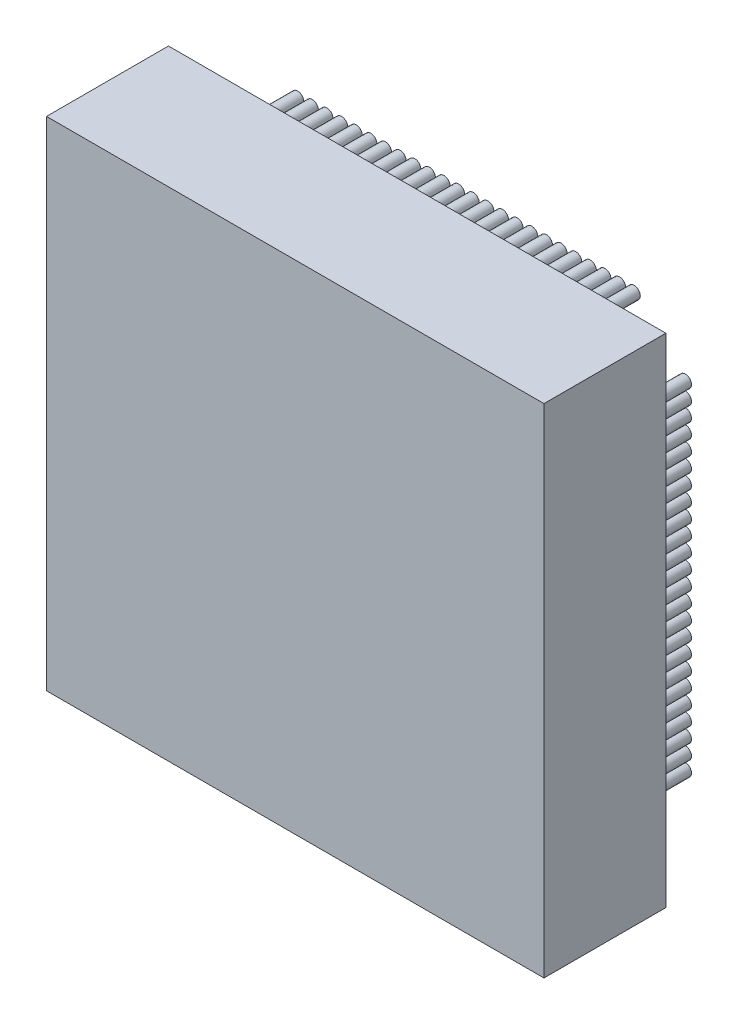
from build123d import *

# Parameters (mm, degrees)
SKETCH1_W               = 20.4
SKETCH1_H               = 20.4
COMPONENT_OUTLINE_DEPTH = 5
SKETCH2_R               = 0.25
EXTRUDE_1_DEPTH         = 2
SKETCH3_R               = 0.25
EXTRUDE_2_DEPTH         = 2
SKETCH4_R               = 0.25
EXTRUDE_3_DEPTH         = 2
SKETCH5_R               = 0.25
EXTRUDE_4_DEPTH         = 2
SKETCH6_R               = 0.25
EXTRUDE_5_DEPTH         = 2
SKETCH7_R               = 0.25
EXTRUDE_6_DEPTH         = 2
SKETCH8_R               = 0.25
EXTRUDE_7_DEPTH         = 2
SKETCH9_R               = 0.25
EXTRUDE_8_DEPTH         = 2
SKETCH10_R              = 0.25
EXTRUDE_9_DEPTH         = 2
SKETCH11_R              = 0.25
EXTRUDE_10_DEPTH        = 2
SKETCH12_R              = 0.25
EXTRUDE_11_DEPTH        = 2
SKETCH13_R              = 0.25
EXTRUDE_12_DEPTH        = 2
SKETCH14_R              = 0.25
EXTRUDE_13_DEPTH        = 2
SKETCH15_R              = 0.25
EXTRUDE_14_DEPTH        = 2
SKETCH16_R              = 0.25
EXTRUDE_15_DEPTH        = 2
SKETCH17_R              = 0.25
EXTRUDE_16_DEPTH        = 2
SKETCH18_R              = 0.25
EXTRUDE_17_DEPTH        = 2
SKETCH19_R              = 0.25
EXTRUDE_18_DEPTH        = 2
SKETCH20_R              = 0.25
EXTRUDE_19_DEPTH        = 2
SKETCH21_R              = 0.25
EXTRUDE_20_DEPTH        = 2
SKETCH22_R              = 0.25
EXTRUDE_21_DEPTH        = 2
SKETCH23_R              = 0.25
EXTRUDE_22_DEPTH        = 2
SKETCH24_R              = 0.25
EXTRUDE_23_DEPTH        = 2
SKETCH25_R              = 0.25
EXTRUDE_24_DEPTH        = 2
SKETCH26_R              = 0.25
EXTRUDE_25_DEPTH        = 2
SKETCH27_R              = 0.25
EXTRUDE_26_DEPTH        = 2
SKETCH28_R              = 0.25
EXTRUDE_27_DEPTH        = 2
SKETCH29_R              = 0.25
EXTRUDE_28_DEPTH        = 2
SKETCH30_R              = 0.25
EXTRUDE_29_DEPTH        = 2
SKETCH31_R              = 0.25
EXTRUDE_30_DEPTH        = 2
SKETCH32_R              = 0.25
EXTRUDE_31_DEPTH        = 2
SKETCH33_R              = 0.25
EXTRUDE_32_DEPTH        = 2
SKETCH34_R              = 0.25
EXTRUDE_33_DEPTH        = 2
SKETCH35_R              = 0.25
EXTRUDE_34_DEPTH        = 2
SKETCH36_R              = 0.25
EXTRUDE_35_DEPTH        = 2
SKETCH37_R              = 0.25
EXTRUDE_36_DEPTH        = 2
SKETCH38_R              = 0.25
EXTRUDE_37_DEPTH        = 2
SKETCH39_R              = 0.25
EXTRUDE_38_DEPTH        = 2
SKETCH40_R              = 0.25
EXTRUDE_39_DEPTH        = 2
SKETCH41_R              = 0.25
EXTRUDE_40_DEPTH        = 2
SKETCH42_R              = 0.25
EXTRUDE_41_DEPTH        = 2
SKETCH43_R              = 0.25
EXTRUDE_42_DEPTH        = 2
SKETCH44_R              = 0.25
EXTRUDE_43_DEPTH        = 2
SKETCH45_R              = 0.25
EXTRUDE_44_DEPTH        = 2
SKETCH46_R              = 0.25
EXTRUDE_45_DEPTH        = 2
SKETCH47_R              = 0.25
EXTRUDE_46_DEPTH        = 2
SKETCH48_R              = 0.25
EXTRUDE_47_DEPTH        = 2
SKETCH49_R              = 0.25
EXTRUDE_48_DEPTH        = 2
SKETCH50_R              = 0.25
EXTRUDE_49_DEPTH        = 2
SKETCH51_R              = 0.25
EXTRUDE_50_DEPTH        = 2
SKETCH52_R              = 0.25
EXTRUDE_51_DEPTH        = 2
SKETCH53_R              = 0.25
EXTRUDE_52_DEPTH        = 2
SKETCH54_R              = 0.25
EXTRUDE_53_DEPTH        = 2
SKETCH55_R              = 0.25
EXTRUDE_54_DEPTH        = 2
SKETCH56_R              = 0.25
EXTRUDE_55_DEPTH        = 2
SKETCH57_R              = 0.25
EXTRUDE_56_DEPTH        = 2
SKETCH58_R              = 0.25
EXTRUDE_57_DEPTH        = 2
SKETCH59_R              = 0.25
EXTRUDE_58_DEPTH        = 2
SKETCH60_R              = 0.25
EXTRUDE_59_DEPTH        = 2
SKETCH61_R              = 0.25
EXTRUDE_60_DEPTH        = 2
SKETCH62_R              = 0.25
EXTRUDE_61_DEPTH        = 2
SKETCH63_R              = 0.25
EXTRUDE_62_DEPTH        = 2
SKETCH64_R              = 0.25
EXTRUDE_63_DEPTH        = 2
SKETCH65_R              = 0.25
EXTRUDE_64_DEPTH        = 2
SKETCH66_R              = 0.25
EXTRUDE_65_DEPTH        = 2
SKETCH67_R              = 0.25
EXTRUDE_66_DEPTH        = 2
SKETCH68_R              = 0.25
EXTRUDE_67_DEPTH        = 2
SKETCH69_R              = 0.25
EXTRUDE_68_DEPTH        = 2
SKETCH70_R              = 0.25
EXTRUDE_69_DEPTH        = 2
SKETCH71_R              = 0.25
EXTRUDE_70_DEPTH        = 2
SKETCH72_R              = 0.25
EXTRUDE_71_DEPTH        = 2
SKETCH73_R              = 0.25
EXTRUDE_72_DEPTH        = 2
SKETCH74_R              = 0.25
EXTRUDE_73_DEPTH        = 2
SKETCH75_R              = 0.25
EXTRUDE_74_DEPTH        = 2
SKETCH76_R              = 0.25
EXTRUDE_75_DEPTH        = 2
SKETCH77_R              = 0.25
EXTRUDE_76_DEPTH        = 2
SKETCH78_R              = 0.25
EXTRUDE_77_DEPTH        = 2
SKETCH79_R              = 0.25
EXTRUDE_78_DEPTH        = 2
SKETCH80_R              = 0.25
EXTRUDE_79_DEPTH        = 2
SKETCH81_R              = 0.25
EXTRUDE_80_DEPTH        = 2
SKETCH82_R              = 0.25
EXTRUDE_81_DEPTH        = 2
SKETCH83_R              = 0.25
EXTRUDE_82_DEPTH        = 2
SKETCH84_R              = 0.25
EXTRUDE_83_DEPTH        = 2
SKETCH85_R              = 0.25
EXTRUDE_84_DEPTH        = 2
SKETCH86_R              = 0.25
EXTRUDE_85_DEPTH        = 2
SKETCH87_R              = 0.25
EXTRUDE_86_DEPTH        = 2
SKETCH88_R              = 0.25
EXTRUDE_87_DEPTH        = 2
SKETCH89_R              = 0.25
EXTRUDE_88_DEPTH        = 2
SKETCH90_R              = 0.25
EXTRUDE_89_DEPTH        = 2
SKETCH91_R              = 0.25
EXTRUDE_90_DEPTH        = 2
SKETCH92_R              = 0.25
EXTRUDE_91_DEPTH        = 2
SKETCH93_R              = 0.25
EXTRUDE_92_DEPTH        = 2
SKETCH94_R              = 0.25
EXTRUDE_93_DEPTH        = 2
SKETCH95_R              = 0.25
EXTRUDE_94_DEPTH        = 2
SKETCH96_R              = 0.25
EXTRUDE_95_DEPTH        = 2
SKETCH97_R              = 0.25
EXTRUDE_96_DEPTH        = 2


with BuildPart() as part:
    # Sketch1 → Component_Outline (new body)
    with BuildSketch(Plane.XY):
        Rectangle(SKETCH1_W, SKETCH1_H)
    extrude(amount=COMPONENT_OUTLINE_DEPTH)


with BuildPart() as body_2:
    # Sketch2 → Extrude 1 (new body)
    with BuildSketch(Plane.XY):
        with Locations((-6.9, -9)):
            Circle(SKETCH2_R)
    extrude(amount=-EXTRUDE_1_DEPTH)


with BuildPart() as body_3:
    # Sketch3 → Extrude 2 (new body)
    with BuildSketch(Plane.XY):
        with Locations((-6.3, -9)):
            Circle(SKETCH3_R)
    extrude(amount=-EXTRUDE_2_DEPTH)


with BuildPart() as body_4:
    # Sketch4 → Extrude 3 (new body)
    with BuildSketch(Plane.XY):
        with Locations((-5.7, -9)):
            Circle(SKETCH4_R)
    extrude(amount=-EXTRUDE_3_DEPTH)


with BuildPart() as body_5:
    # Sketch5 → Extrude 4 (new body)
    with BuildSketch(Plane.XY):
        with Locations((-5.1, -9)):
            Circle(SKETCH5_R)
    extrude(amount=-EXTRUDE_4_DEPTH)


with BuildPart() as body_6:
    # Sketch6 → Extrude 5 (new body)
    with BuildSketch(Plane.XY):
        with Locations((-4.5, -9)):
            Circle(SKETCH6_R)
    extrude(amount=-EXTRUDE_5_DEPTH)


with BuildPart() as body_7:
    # Sketch7 → Extrude 6 (new body)
    with BuildSketch(Plane.XY):
        with Locations((-3.9, -9)):
            Circle(SKETCH7_R)
    extrude(amount=-EXTRUDE_6_DEPTH)


with BuildPart() as body_8:
    # Sketch8 → Extrude 7 (new body)
    with BuildSketch(Plane.XY):
        with Locations((-3.3, -9)):
            Circle(SKETCH8_R)
    extrude(amount=-EXTRUDE_7_DEPTH)


with BuildPart() as body_9:
    # Sketch9 → Extrude 8 (new body)
    with BuildSketch(Plane.XY):
        with Locations((-2.7, -9)):
            Circle(SKETCH9_R)
    extrude(amount=-EXTRUDE_8_DEPTH)


with BuildPart() as body_10:
    # Sketch10 → Extrude 9 (new body)
    with BuildSketch(Plane.XY):
        with Locations((-2.1, -9)):
            Circle(SKETCH10_R)
    extrude(amount=-EXTRUDE_9_DEPTH)


with BuildPart() as body_11:
    # Sketch11 → Extrude 10 (new body)
    with BuildSketch(Plane.XY):
        with Locations((-1.5, -9)):
            Circle(SKETCH11_R)
    extrude(amount=-EXTRUDE_10_DEPTH)


with BuildPart() as body_12:
    # Sketch12 → Extrude 11 (new body)
    with BuildSketch(Plane.XY):
        with Locations((-0.9, -9)):
            Circle(SKETCH12_R)
    extrude(amount=-EXTRUDE_11_DEPTH)


with BuildPart() as body_13:
    # Sketch13 → Extrude 12 (new body)
    with BuildSketch(Plane.XY):
        with Locations((-0.3, -9)):
            Circle(SKETCH13_R)
    extrude(amount=-EXTRUDE_12_DEPTH)


with BuildPart() as body_14:
    # Sketch14 → Extrude 13 (new body)
    with BuildSketch(Plane.XY):
        with Locations((0.3, -9)):
            Circle(SKETCH14_R)
    extrude(amount=-EXTRUDE_13_DEPTH)


with BuildPart() as body_15:
    # Sketch15 → Extrude 14 (new body)
    with BuildSketch(Plane.XY):
        with Locations((0.9, -9)):
            Circle(SKETCH15_R)
    extrude(amount=-EXTRUDE_14_DEPTH)


with BuildPart() as body_16:
    # Sketch16 → Extrude 15 (new body)
    with BuildSketch(Plane.XY):
        with Locations((1.5, -9)):
            Circle(SKETCH16_R)
    extrude(amount=-EXTRUDE_15_DEPTH)


with BuildPart() as body_17:
    # Sketch17 → Extrude 16 (new body)
    with BuildSketch(Plane.XY):
        with Locations((2.1, -9)):
            Circle(SKETCH17_R)
    extrude(amount=-EXTRUDE_16_DEPTH)


with BuildPart() as body_18:
    # Sketch18 → Extrude 17 (new body)
    with BuildSketch(Plane.XY):
        with Locations((2.7, -9)):
            Circle(SKETCH18_R)
    extrude(amount=-EXTRUDE_17_DEPTH)


with BuildPart() as body_19:
    # Sketch19 → Extrude 18 (new body)
    with BuildSketch(Plane.XY):
        with Locations((3.3, -9)):
            Circle(SKETCH19_R)
    extrude(amount=-EXTRUDE_18_DEPTH)


with BuildPart() as body_20:
    # Sketch20 → Extrude 19 (new body)
    with BuildSketch(Plane.XY):
        with Locations((3.9, -9)):
            Circle(SKETCH20_R)
    extrude(amount=-EXTRUDE_19_DEPTH)


with BuildPart() as body_21:
    # Sketch21 → Extrude 20 (new body)
    with BuildSketch(Plane.XY):
        with Locations((4.5, -9)):
            Circle(SKETCH21_R)
    extrude(amount=-EXTRUDE_20_DEPTH)


with BuildPart() as body_22:
    # Sketch22 → Extrude 21 (new body)
    with BuildSketch(Plane.XY):
        with Locations((5.1, -9)):
            Circle(SKETCH22_R)
    extrude(amount=-EXTRUDE_21_DEPTH)


with BuildPart() as body_23:
    # Sketch23 → Extrude 22 (new body)
    with BuildSketch(Plane.XY):
        with Locations((5.7, -9)):
            Circle(SKETCH23_R)
    extrude(amount=-EXTRUDE_22_DEPTH)


with BuildPart() as body_24:
    # Sketch24 → Extrude 23 (new body)
    with BuildSketch(Plane.XY):
        with Locations((6.3, -9)):
            Circle(SKETCH24_R)
    extrude(amount=-EXTRUDE_23_DEPTH)


with BuildPart() as body_25:
    # Sketch25 → Extrude 24 (new body)
    with BuildSketch(Plane.XY):
        with Locations((6.9, -9)):
            Circle(SKETCH25_R)
    extrude(amount=-EXTRUDE_24_DEPTH)


with BuildPart() as body_26:
    # Sketch26 → Extrude 25 (new body)
    with BuildSketch(Plane.XY):
        with Locations((9, -6.9)):
            Circle(SKETCH26_R)
    extrude(amount=-EXTRUDE_25_DEPTH)


with BuildPart() as body_27:
    # Sketch27 → Extrude 26 (new body)
    with BuildSketch(Plane.XY):
        with Locations((9, -6.3)):
            Circle(SKETCH27_R)
    extrude(amount=-EXTRUDE_26_DEPTH)


with BuildPart() as body_28:
    # Sketch28 → Extrude 27 (new body)
    with BuildSketch(Plane.XY):
        with Locations((9, -5.7)):
            Circle(SKETCH28_R)
    extrude(amount=-EXTRUDE_27_DEPTH)


with BuildPart() as body_29:
    # Sketch29 → Extrude 28 (new body)
    with BuildSketch(Plane.XY):
        with Locations((9, -5.1)):
            Circle(SKETCH29_R)
    extrude(amount=-EXTRUDE_28_DEPTH)


with BuildPart() as body_30:
    # Sketch30 → Extrude 29 (new body)
    with BuildSketch(Plane.XY):
        with Locations((9, -4.5)):
            Circle(SKETCH30_R)
    extrude(amount=-EXTRUDE_29_DEPTH)


with BuildPart() as body_31:
    # Sketch31 → Extrude 30 (new body)
    with BuildSketch(Plane.XY):
        with Locations((9, -3.9)):
            Circle(SKETCH31_R)
    extrude(amount=-EXTRUDE_30_DEPTH)


with BuildPart() as body_32:
    # Sketch32 → Extrude 31 (new body)
    with BuildSketch(Plane.XY):
        with Locations((9, -3.3)):
            Circle(SKETCH32_R)
    extrude(amount=-EXTRUDE_31_DEPTH)


with BuildPart() as body_33:
    # Sketch33 → Extrude 32 (new body)
    with BuildSketch(Plane.XY):
        with Locations((9, -2.7)):
            Circle(SKETCH33_R)
    extrude(amount=-EXTRUDE_32_DEPTH)


with BuildPart() as body_34:
    # Sketch34 → Extrude 33 (new body)
    with BuildSketch(Plane.XY):
        with Locations((9, -2.1)):
            Circle(SKETCH34_R)
    extrude(amount=-EXTRUDE_33_DEPTH)


with BuildPart() as body_35:
    # Sketch35 → Extrude 34 (new body)
    with BuildSketch(Plane.XY):
        with Locations((9, -1.5)):
            Circle(SKETCH35_R)
    extrude(amount=-EXTRUDE_34_DEPTH)


with BuildPart() as body_36:
    # Sketch36 → Extrude 35 (new body)
    with BuildSketch(Plane.XY):
        with Locations((9, -0.9)):
            Circle(SKETCH36_R)
    extrude(amount=-EXTRUDE_35_DEPTH)


with BuildPart() as body_37:
    # Sketch37 → Extrude 36 (new body)
    with BuildSketch(Plane.XY):
        with Locations((9, -0.3)):
            Circle(SKETCH37_R)
    extrude(amount=-EXTRUDE_36_DEPTH)


with BuildPart() as body_38:
    # Sketch38 → Extrude 37 (new body)
    with BuildSketch(Plane.XY):
        with Locations((9, 0.3)):
            Circle(SKETCH38_R)
    extrude(amount=-EXTRUDE_37_DEPTH)


with BuildPart() as body_39:
    # Sketch39 → Extrude 38 (new body)
    with BuildSketch(Plane.XY):
        with Locations((9, 0.9)):
            Circle(SKETCH39_R)
    extrude(amount=-EXTRUDE_38_DEPTH)


with BuildPart() as body_40:
    # Sketch40 → Extrude 39 (new body)
    with BuildSketch(Plane.XY):
        with Locations((9, 1.5)):
            Circle(SKETCH40_R)
    extrude(amount=-EXTRUDE_39_DEPTH)


with BuildPart() as body_41:
    # Sketch41 → Extrude 40 (new body)
    with BuildSketch(Plane.XY):
        with Locations((9, 2.1)):
            Circle(SKETCH41_R)
    extrude(amount=-EXTRUDE_40_DEPTH)


with BuildPart() as body_42:
    # Sketch42 → Extrude 41 (new body)
    with BuildSketch(Plane.XY):
        with Locations((9, 2.7)):
            Circle(SKETCH42_R)
    extrude(amount=-EXTRUDE_41_DEPTH)


with BuildPart() as body_43:
    # Sketch43 → Extrude 42 (new body)
    with BuildSketch(Plane.XY):
        with Locations((9, 3.3)):
            Circle(SKETCH43_R)
    extrude(amount=-EXTRUDE_42_DEPTH)


with BuildPart() as body_44:
    # Sketch44 → Extrude 43 (new body)
    with BuildSketch(Plane.XY):
        with Locations((9, 3.9)):
            Circle(SKETCH44_R)
    extrude(amount=-EXTRUDE_43_DEPTH)


with BuildPart() as body_45:
    # Sketch45 → Extrude 44 (new body)
    with BuildSketch(Plane.XY):
        with Locations((9, 4.5)):
            Circle(SKETCH45_R)
    extrude(amount=-EXTRUDE_44_DEPTH)


with BuildPart() as body_46:
    # Sketch46 → Extrude 45 (new body)
    with BuildSketch(Plane.XY):
        with Locations((9, 5.1)):
            Circle(SKETCH46_R)
    extrude(amount=-EXTRUDE_45_DEPTH)


with BuildPart() as body_47:
    # Sketch47 → Extrude 46 (new body)
    with BuildSketch(Plane.XY):
        with Locations((9, 5.7)):
            Circle(SKETCH47_R)
    extrude(amount=-EXTRUDE_46_DEPTH)


with BuildPart() as body_48:
    # Sketch48 → Extrude 47 (new body)
    with BuildSketch(Plane.XY):
        with Locations((9, 6.3)):
            Circle(SKETCH48_R)
    extrude(amount=-EXTRUDE_47_DEPTH)


with BuildPart() as body_49:
    # Sketch49 → Extrude 48 (new body)
    with BuildSketch(Plane.XY):
        with Locations((9, 6.9)):
            Circle(SKETCH49_R)
    extrude(amount=-EXTRUDE_48_DEPTH)


with BuildPart() as body_50:
    # Sketch50 → Extrude 49 (new body)
    with BuildSketch(Plane.XY):
        with Locations((6.9, 9)):
            Circle(SKETCH50_R)
    extrude(amount=-EXTRUDE_49_DEPTH)


with BuildPart() as body_51:
    # Sketch51 → Extrude 50 (new body)
    with BuildSketch(Plane.XY):
        with Locations((6.3, 9)):
            Circle(SKETCH51_R)
    extrude(amount=-EXTRUDE_50_DEPTH)


with BuildPart() as body_52:
    # Sketch52 → Extrude 51 (new body)
    with BuildSketch(Plane.XY):
        with Locations((5.7, 9)):
            Circle(SKETCH52_R)
    extrude(amount=-EXTRUDE_51_DEPTH)


with BuildPart() as body_53:
    # Sketch53 → Extrude 52 (new body)
    with BuildSketch(Plane.XY):
        with Locations((5.1, 9)):
            Circle(SKETCH53_R)
    extrude(amount=-EXTRUDE_52_DEPTH)


with BuildPart() as body_54:
    # Sketch54 → Extrude 53 (new body)
    with BuildSketch(Plane.XY):
        with Locations((4.5, 9)):
            Circle(SKETCH54_R)
    extrude(amount=-EXTRUDE_53_DEPTH)


with BuildPart() as body_55:
    # Sketch55 → Extrude 54 (new body)
    with BuildSketch(Plane.XY):
        with Locations((3.9, 9)):
            Circle(SKETCH55_R)
    extrude(amount=-EXTRUDE_54_DEPTH)


with BuildPart() as body_56:
    # Sketch56 → Extrude 55 (new body)
    with BuildSketch(Plane.XY):
        with Locations((3.3, 9)):
            Circle(SKETCH56_R)
    extrude(amount=-EXTRUDE_55_DEPTH)


with BuildPart() as body_57:
    # Sketch57 → Extrude 56 (new body)
    with BuildSketch(Plane.XY):
        with Locations((2.7, 9)):
            Circle(SKETCH57_R)
    extrude(amount=-EXTRUDE_56_DEPTH)


with BuildPart() as body_58:
    # Sketch58 → Extrude 57 (new body)
    with BuildSketch(Plane.XY):
        with Locations((2.1, 9)):
            Circle(SKETCH58_R)
    extrude(amount=-EXTRUDE_57_DEPTH)


with BuildPart() as body_59:
    # Sketch59 → Extrude 58 (new body)
    with BuildSketch(Plane.XY):
        with Locations((1.5, 9)):
            Circle(SKETCH59_R)
    extrude(amount=-EXTRUDE_58_DEPTH)


with BuildPart() as body_60:
    # Sketch60 → Extrude 59 (new body)
    with BuildSketch(Plane.XY):
        with Locations((0.9, 9)):
            Circle(SKETCH60_R)
    extrude(amount=-EXTRUDE_59_DEPTH)


with BuildPart() as body_61:
    # Sketch61 → Extrude 60 (new body)
    with BuildSketch(Plane.XY):
        with Locations((0.3, 9)):
            Circle(SKETCH61_R)
    extrude(amount=-EXTRUDE_60_DEPTH)


with BuildPart() as body_62:
    # Sketch62 → Extrude 61 (new body)
    with BuildSketch(Plane.XY):
        with Locations((-0.3, 9)):
            Circle(SKETCH62_R)
    extrude(amount=-EXTRUDE_61_DEPTH)


with BuildPart() as body_63:
    # Sketch63 → Extrude 62 (new body)
    with BuildSketch(Plane.XY):
        with Locations((-0.9, 9)):
            Circle(SKETCH63_R)
    extrude(amount=-EXTRUDE_62_DEPTH)


with BuildPart() as body_64:
    # Sketch64 → Extrude 63 (new body)
    with BuildSketch(Plane.XY):
        with Locations((-1.5, 9)):
            Circle(SKETCH64_R)
    extrude(amount=-EXTRUDE_63_DEPTH)


with BuildPart() as body_65:
    # Sketch65 → Extrude 64 (new body)
    with BuildSketch(Plane.XY):
        with Locations((-2.1, 9)):
            Circle(SKETCH65_R)
    extrude(amount=-EXTRUDE_64_DEPTH)


with BuildPart() as body_66:
    # Sketch66 → Extrude 65 (new body)
    with BuildSketch(Plane.XY):
        with Locations((-2.7, 9)):
            Circle(SKETCH66_R)
    extrude(amount=-EXTRUDE_65_DEPTH)


with BuildPart() as body_67:
    # Sketch67 → Extrude 66 (new body)
    with BuildSketch(Plane.XY):
        with Locations((-3.3, 9)):
            Circle(SKETCH67_R)
    extrude(amount=-EXTRUDE_66_DEPTH)


with BuildPart() as body_68:
    # Sketch68 → Extrude 67 (new body)
    with BuildSketch(Plane.XY):
        with Locations((-3.9, 9)):
            Circle(SKETCH68_R)
    extrude(amount=-EXTRUDE_67_DEPTH)


with BuildPart() as body_69:
    # Sketch69 → Extrude 68 (new body)
    with BuildSketch(Plane.XY):
        with Locations((-4.5, 9)):
            Circle(SKETCH69_R)
    extrude(amount=-EXTRUDE_68_DEPTH)


with BuildPart() as body_70:
    # Sketch70 → Extrude 69 (new body)
    with BuildSketch(Plane.XY):
        with Locations((-5.1, 9)):
            Circle(SKETCH70_R)
    extrude(amount=-EXTRUDE_69_DEPTH)


with BuildPart() as body_71:
    # Sketch71 → Extrude 70 (new body)
    with BuildSketch(Plane.XY):
        with Locations((-5.7, 9)):
            Circle(SKETCH71_R)
    extrude(amount=-EXTRUDE_70_DEPTH)


with BuildPart() as body_72:
    # Sketch72 → Extrude 71 (new body)
    with BuildSketch(Plane.XY):
        with Locations((-6.3, 9)):
            Circle(SKETCH72_R)
    extrude(amount=-EXTRUDE_71_DEPTH)


with BuildPart() as body_73:
    # Sketch73 → Extrude 72 (new body)
    with BuildSketch(Plane.XY):
        with Locations((-6.9, 9)):
            Circle(SKETCH73_R)
    extrude(amount=-EXTRUDE_72_DEPTH)


with BuildPart() as body_74:
    # Sketch74 → Extrude 73 (new body)
    with BuildSketch(Plane.XY):
        with Locations((-9, 6.9)):
            Circle(SKETCH74_R)
    extrude(amount=-EXTRUDE_73_DEPTH)


with BuildPart() as body_75:
    # Sketch75 → Extrude 74 (new body)
    with BuildSketch(Plane.XY):
        with Locations((-9, 6.3)):
            Circle(SKETCH75_R)
    extrude(amount=-EXTRUDE_74_DEPTH)


with BuildPart() as body_76:
    # Sketch76 → Extrude 75 (new body)
    with BuildSketch(Plane.XY):
        with Locations((-9, 5.7)):
            Circle(SKETCH76_R)
    extrude(amount=-EXTRUDE_75_DEPTH)


with BuildPart() as body_77:
    # Sketch77 → Extrude 76 (new body)
    with BuildSketch(Plane.XY):
        with Locations((-9, 5.1)):
            Circle(SKETCH77_R)
    extrude(amount=-EXTRUDE_76_DEPTH)


with BuildPart() as body_78:
    # Sketch78 → Extrude 77 (new body)
    with BuildSketch(Plane.XY):
        with Locations((-9, 4.5)):
            Circle(SKETCH78_R)
    extrude(amount=-EXTRUDE_77_DEPTH)


with BuildPart() as body_79:
    # Sketch79 → Extrude 78 (new body)
    with BuildSketch(Plane.XY):
        with Locations((-9, 3.9)):
            Circle(SKETCH79_R)
    extrude(amount=-EXTRUDE_78_DEPTH)


with BuildPart() as body_80:
    # Sketch80 → Extrude 79 (new body)
    with BuildSketch(Plane.XY):
        with Locations((-9, 3.3)):
            Circle(SKETCH80_R)
    extrude(amount=-EXTRUDE_79_DEPTH)


with BuildPart() as body_81:
    # Sketch81 → Extrude 80 (new body)
    with BuildSketch(Plane.XY):
        with Locations((-9, 2.7)):
            Circle(SKETCH81_R)
    extrude(amount=-EXTRUDE_80_DEPTH)


with BuildPart() as body_82:
    # Sketch82 → Extrude 81 (new body)
    with BuildSketch(Plane.XY):
        with Locations((-9, 2.1)):
            Circle(SKETCH82_R)
    extrude(amount=-EXTRUDE_81_DEPTH)


with BuildPart() as body_83:
    # Sketch83 → Extrude 82 (new body)
    with BuildSketch(Plane.XY):
        with Locations((-9, 1.5)):
            Circle(SKETCH83_R)
    extrude(amount=-EXTRUDE_82_DEPTH)


with BuildPart() as body_84:
    # Sketch84 → Extrude 83 (new body)
    with BuildSketch(Plane.XY):
        with Locations((-9, 0.9)):
            Circle(SKETCH84_R)
    extrude(amount=-EXTRUDE_83_DEPTH)


with BuildPart() as body_85:
    # Sketch85 → Extrude 84 (new body)
    with BuildSketch(Plane.XY):
        with Locations((-9, 0.3)):
            Circle(SKETCH85_R)
    extrude(amount=-EXTRUDE_84_DEPTH)


with BuildPart() as body_86:
    # Sketch86 → Extrude 85 (new body)
    with BuildSketch(Plane.XY):
        with Locations((-9, -0.3)):
            Circle(SKETCH86_R)
    extrude(amount=-EXTRUDE_85_DEPTH)


with BuildPart() as body_87:
    # Sketch87 → Extrude 86 (new body)
    with BuildSketch(Plane.XY):
        with Locations((-9, -0.9)):
            Circle(SKETCH87_R)
    extrude(amount=-EXTRUDE_86_DEPTH)


with BuildPart() as body_88:
    # Sketch88 → Extrude 87 (new body)
    with BuildSketch(Plane.XY):
        with Locations((-9, -1.5)):
            Circle(SKETCH88_R)
    extrude(amount=-EXTRUDE_87_DEPTH)


with BuildPart() as body_89:
    # Sketch89 → Extrude 88 (new body)
    with BuildSketch(Plane.XY):
        with Locations((-9, -2.1)):
            Circle(SKETCH89_R)
    extrude(amount=-EXTRUDE_88_DEPTH)


with BuildPart() as body_90:
    # Sketch90 → Extrude 89 (new body)
    with BuildSketch(Plane.XY):
        with Locations((-9, -2.7)):
            Circle(SKETCH90_R)
    extrude(amount=-EXTRUDE_89_DEPTH)


with BuildPart() as body_91:
    # Sketch91 → Extrude 90 (new body)
    with BuildSketch(Plane.XY):
        with Locations((-9, -3.3)):
            Circle(SKETCH91_R)
    extrude(amount=-EXTRUDE_90_DEPTH)


with BuildPart() as body_92:
    # Sketch92 → Extrude 91 (new body)
    with BuildSketch(Plane.XY):
        with Locations((-9, -3.9)):
            Circle(SKETCH92_R)
    extrude(amount=-EXTRUDE_91_DEPTH)


with BuildPart() as body_93:
    # Sketch93 → Extrude 92 (new body)
    with BuildSketch(Plane.XY):
        with Locations((-9, -4.5)):
            Circle(SKETCH93_R)
    extrude(amount=-EXTRUDE_92_DEPTH)


with BuildPart() as body_94:
    # Sketch94 → Extrude 93 (new body)
    with BuildSketch(Plane.XY):
        with Locations((-9, -5.1)):
            Circle(SKETCH94_R)
    extrude(amount=-EXTRUDE_93_DEPTH)


with BuildPart() as body_95:
    # Sketch95 → Extrude 94 (new body)
    with BuildSketch(Plane.XY):
        with Locations((-9, -5.7)):
            Circle(SKETCH95_R)
    extrude(amount=-EXTRUDE_94_DEPTH)


with BuildPart() as body_96:
    # Sketch96 → Extrude 95 (new body)
    with BuildSketch(Plane.XY):
        with Locations((-9, -6.3)):
            Circle(SKETCH96_R)
    extrude(amount=-EXTRUDE_95_DEPTH)


with BuildPart() as body_97:
    # Sketch97 → Extrude 96 (new body)
    with BuildSketch(Plane.XY):
        with Locations((-9, -6.9)):
            Circle(SKETCH97_R)
    extrude(amount=-EXTRUDE_96_DEPTH)


solid = Compound([part.part, body_2.part, body_3.part, body_4.part, body_5.part, body_6.part, body_7.part, body_8.part, body_9.part, body_10.part, body_11.part, body_12.part, body_13.part, body_14.part, body_15.part, body_16.part, body_17.part, body_18.part, body_19.part, body_20.part, body_21.part, body_22.part, body_23.part, body_24.part, body_25.part, body_26.part, body_27.part, body_28.part, body_29.part, body_30.part, body_31.part, body_32.part, body_33.part, body_34.part, body_35.part, body_36.part, body_37.part, body_38.part, body_39.part, body_40.part, body_41.part, body_42.part, body_43.part, body_44.part, body_45.part, body_46.part, body_47.part, body_48.part, body_49.part, body_50.part, body_51.part, body_52.part, body_53.part, body_54.part, body_55.part, body_56.part, body_57.part, body_58.part, body_59.part, body_60.part, body_61.part, body_62.part, body_63.part, body_64.part, body_65.part, body_66.part, body_67.part, body_68.part, body_69.part, body_70.part, body_71.part, body_72.part, body_73.part, body_74.part, body_75.part, body_76.part, body_77.part, body_78.part, body_79.part, body_80.part, body_81.part, body_82.part, body_83.part, body_84.part, body_85.part, body_86.part, body_87.part, body_88.part, body_89.part, body_90.part, body_91.part, body_92.part, body_93.part, body_94.part, body_95.part, body_96.part, body_97.part])
